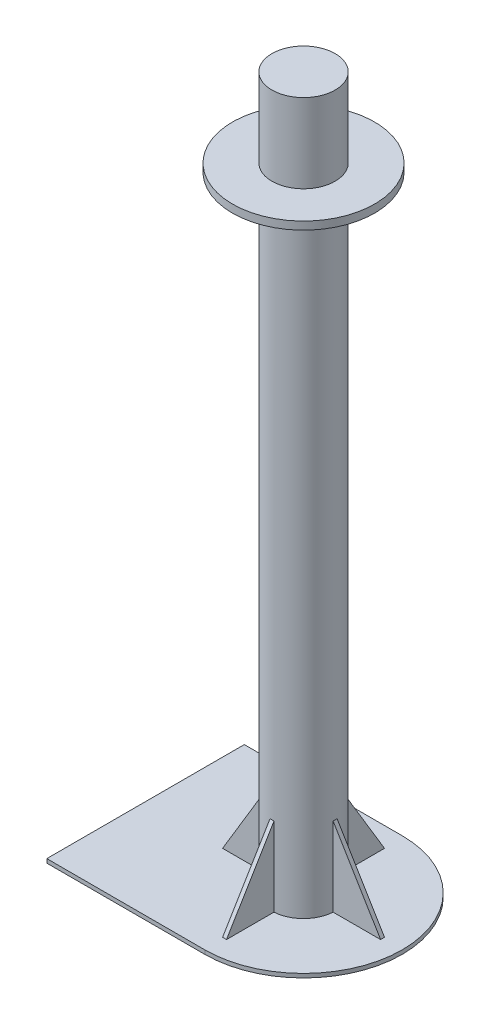
from build123d import *

# Parameters (mm, degrees)
EXTRUDE_2_DEPTH     = 5
SKETCH_5_R          = 40
EXTRUDE_5_DEPTH     = 100
EXTRUDE_6_DEPTH     = 100
CUT_EXTRUDE_1_DEPTH = 10
CUT_EXTRUDE_2_DEPTH = 10
CUT_EXTRUDE_3_DEPTH = 10
CUT_EXTRUDE_4_DEPTH = 10
SKETCH_11_R         = 40
EXTRUDE_7_DEPTH     = 690
SKETCH_12_R         = 90
EXTRUDE_8_DEPTH     = 10
SKETCH_13_R         = 40
EXTRUDE_9_DEPTH     = 100


with BuildPart() as part:
    # 草图1 → 凸台-拉伸2 (new body)
    with BuildSketch(Plane(origin=(0, 0, 0), x_dir=(1, 0, 0), z_dir=(0, 1, 0))):
        with BuildLine():
            Line((100, -125), (-100, -125))
            Line((-100, -125), (-100, 125))
            Line((-100, 125), (100, 125))
            ThreePointArc((100, 125), (225, 0), (100, -125))
        make_face()
    extrude(amount=EXTRUDE_2_DEPTH)

    # 草图5 → 凸台-拉伸5 (add)
    with BuildSketch(Plane(origin=(0, 5, 0), x_dir=(1, 0, 0), z_dir=(0, 1, 0))):
        with Locations((100, 0)):
            Circle(SKETCH_5_R)
    extrude(amount=EXTRUDE_5_DEPTH)

    # 草图6 → 凸台-拉伸6 (add)
    with BuildSketch(Plane(origin=(0, 5, 0), x_dir=(1, 0, 0), z_dir=(0, 1, 0))):
        with BuildLine():
            Line((102.5, -100), (97.5, -100))
            Line((97.5, -100), (97.5, -39.921798557))
            ThreePointArc((97.5, -39.921798557), (100, -40), (102.5, -39.921798557))
            Line((102.5, -39.921798557), (102.5, -100))
        make_face()
        with BuildLine():
            Line((0, -2.5), (0, 2.5))
            Line((0, 2.5), (60.078201443, 2.5))
            ThreePointArc((60.078201443, 2.5), (60, 0), (60.078201443, -2.5))
            Line((60.078201443, -2.5), (0, -2.5))
        make_face()
        with BuildLine():
            Line((102.5, 100), (97.5, 100))
            Line((97.5, 100), (97.5, 39.921798557))
            ThreePointArc((97.5, 39.921798557), (100, 40), (102.5, 39.921798557))
            Line((102.5, 39.921798557), (102.5, 100))
        make_face()
        with BuildLine():
            Line((200, -2.5), (200, 2.5))
            Line((200, 2.5), (139.921798557, 2.5))
            ThreePointArc((139.921798557, 2.5), (140, 0), (139.921798557, -2.5))
            Line((139.921798557, -2.5), (200, -2.5))
        make_face()
    extrude(amount=EXTRUDE_6_DEPTH)

    # 草图7 → 切除-拉伸1 (cut)
    with BuildSketch(Plane.ZY.offset(-97.5)):
        Polygon((39.921798557, 105), (100, 5), (100, 105), align=None)
    extrude(amount=-CUT_EXTRUDE_1_DEPTH, mode=Mode.SUBTRACT)

    # 草图8 → 切除-拉伸2 (cut)
    with BuildSketch(Plane.XY.offset(2.5)):
        Polygon((139.921798557, 105), (200, 5), (200, 105), align=None)
    extrude(amount=-CUT_EXTRUDE_2_DEPTH, mode=Mode.SUBTRACT)

    # 草图9 → 切除-拉伸3 (cut)
    with BuildSketch(Plane(origin=(102.5, 0, 0), x_dir=(0, 0, -1), z_dir=(1, 0, 0))):
        Polygon((39.921798557, 105), (100, 105), (100, 5), align=None)
    extrude(amount=-CUT_EXTRUDE_3_DEPTH, mode=Mode.SUBTRACT)

    # 草图10 → 切除-拉伸4 (cut)
    with BuildSketch(Plane(origin=(0, 0, -2.5), x_dir=(-1, 0, 0), z_dir=(0, 0, -1))):
        Polygon((0, 105), (0, 5), (-60.078201443, 105), align=None)
    extrude(amount=-CUT_EXTRUDE_4_DEPTH, mode=Mode.SUBTRACT)

    # 草图11 → 凸台-拉伸7 (add)
    with BuildSketch(Plane(origin=(0, 105, 0), x_dir=(1, 0, 0), z_dir=(0, 1, 0))):
        with Locations((100, 0)):
            Circle(SKETCH_11_R)
    extrude(amount=EXTRUDE_7_DEPTH)

    # 草图12 → 凸台-拉伸8 (add)
    with BuildSketch(Plane(origin=(0, 795, 0), x_dir=(1, 0, 0), z_dir=(0, 1, 0))):
        with Locations((100, 0)):
            Circle(SKETCH_12_R)
    extrude(amount=EXTRUDE_8_DEPTH)

    # 草图13 → 凸台-拉伸9 (add)
    with BuildSketch(Plane(origin=(0, 805, 0), x_dir=(1, 0, 0), z_dir=(0, 1, 0))):
        with Locations((100, 0)):
            Circle(SKETCH_13_R)
    extrude(amount=EXTRUDE_9_DEPTH)


solid = part.part
